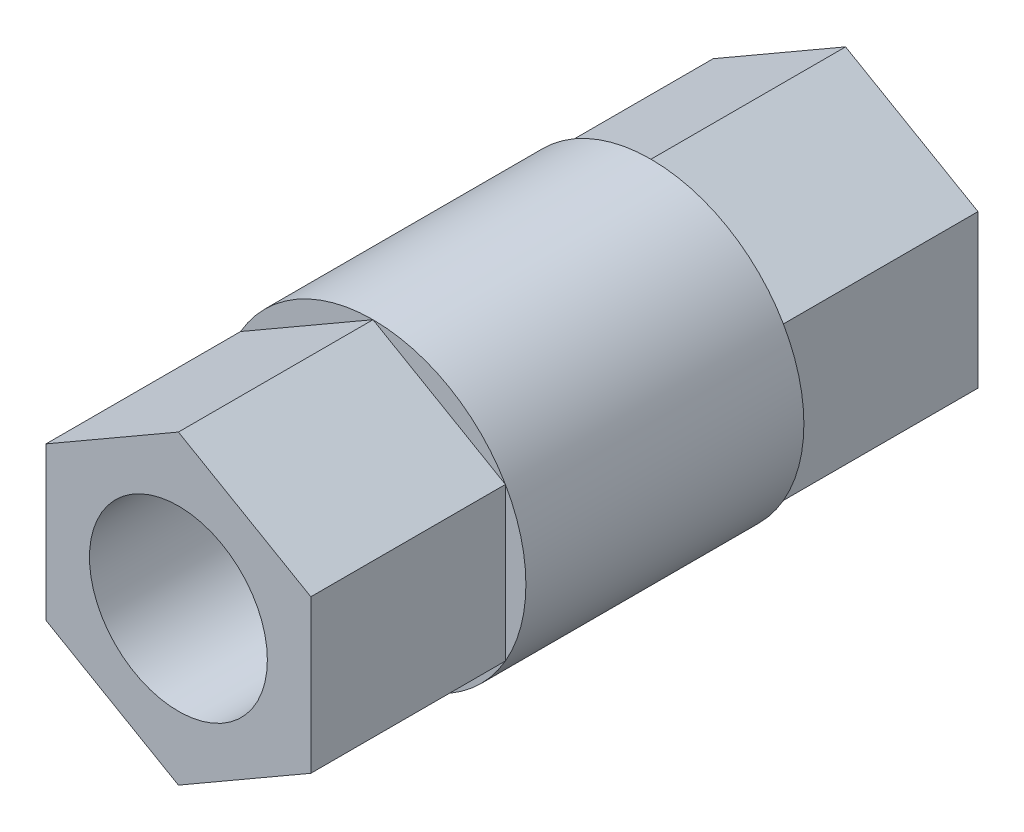
from build123d import *

# Parameters (mm, degrees)
SKETCH1_R           = 11
SKETCH1_R_2         = 6.4
BOSS_EXTRUDE1_DEPTH = 10
SKETCH1_3_R         = 6.4
BOSS_EXTRUDE2_DEPTH = 24


with BuildPart() as part:
    # Sketch1 → Boss-Extrude1 (new, symmetric)
    with BuildSketch(Plane.XY):
        Circle(SKETCH1_R)
        Circle(SKETCH1_R_2, mode=Mode.SUBTRACT)
    extrude(amount=BOSS_EXTRUDE1_DEPTH, both=True)

    # Sketch1_3 → Boss-Extrude2 (add, symmetric)
    with BuildSketch(Plane.XY):
        Polygon((-9.526279442, -5.5), (0, -11), (9.526279442, -5.5), (9.526279442, 5.5), (0, 11), (-9.526279442, 5.5), align=None)
        Circle(SKETCH1_3_R, mode=Mode.SUBTRACT)
    extrude(amount=BOSS_EXTRUDE2_DEPTH, both=True)


solid = part.part
